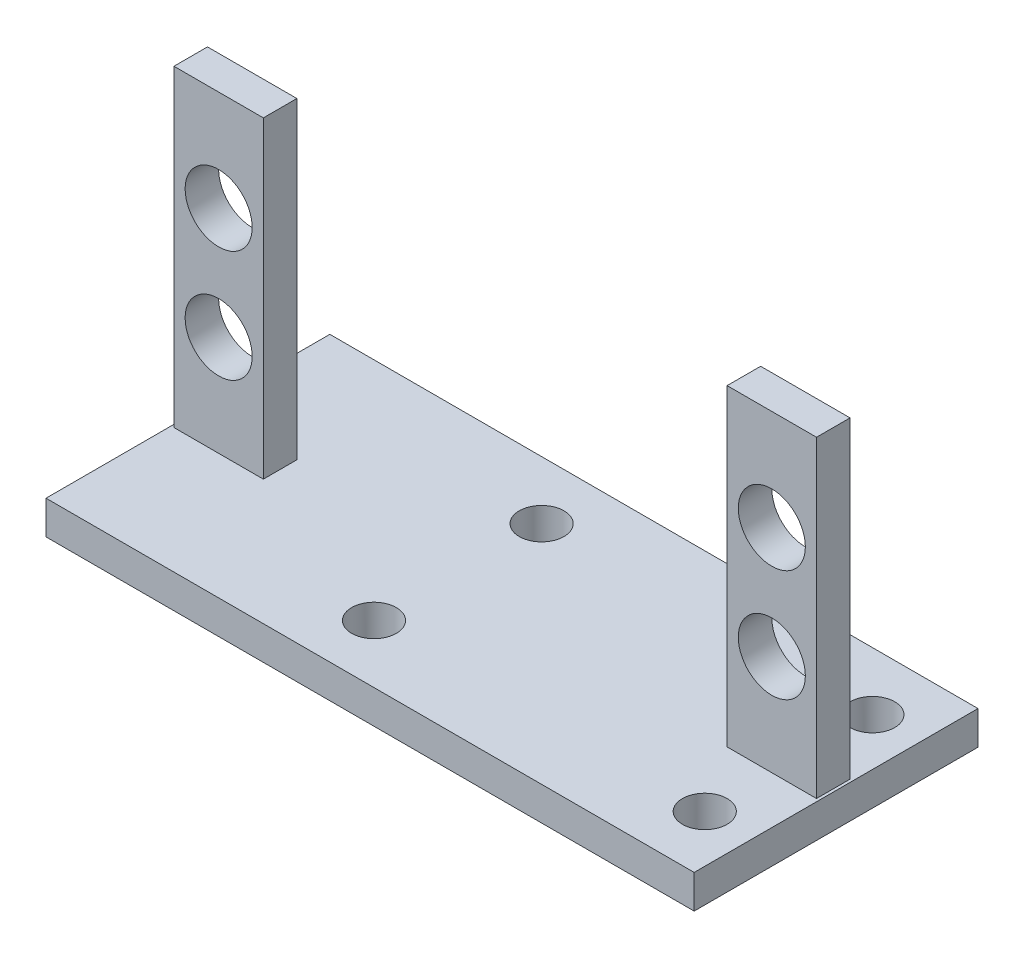
from build123d import *

# Parameters (mm, degrees)
SKETCH_1_W          = 58
SKETCH_1_H          = 25.4
EXTRUDE_1_DEPTH     = 3
SKETCH_2_W          = 8
SKETCH_2_H          = 3
EXTRUDE_2_DEPTH     = 28
SKETCH_3_R          = 3
CUT_EXTRUDE_1_DEPTH = 12
SKETCH_4_R          = 2
CUT_EXTRUDE_2_DEPTH = 22
SKETCH_5_W          = 8
SKETCH_5_H          = 3
CUT_EXTRUDE_3_DEPTH = 28


with BuildPart() as part:
    # 草图1 → 凸台-拉伸1 (new body)
    with BuildSketch(Plane(origin=(0, 0, 0), x_dir=(1, 0, 0), z_dir=(0, 1, 0))):
        Rectangle(SKETCH_1_W, SKETCH_1_H)
    extrude(amount=EXTRUDE_1_DEPTH)

    # 草图2 → 凸台-拉伸2 (add)
    with BuildSketch(Plane(origin=(0, 3, 0), x_dir=(1, 0, 0), z_dir=(0, 1, 0))):
        with Locations((-24.75, 11.2)):
            Rectangle(SKETCH_2_W, SKETCH_2_H)
        with Locations((24.75, 11.2)):
            Rectangle(SKETCH_2_W, SKETCH_2_H)
        with Locations((-24.75, 0)):
            Rectangle(SKETCH_2_W, SKETCH_2_H)
        with Locations((24.75, 0)):
            Rectangle(SKETCH_2_W, SKETCH_2_H)
    extrude(amount=EXTRUDE_2_DEPTH)

    # 草图3 → 切除-拉伸1 (cut, symmetric)
    with BuildSketch(Plane.XY.offset(-9.7)):
        with Locations((-24.75, 12)):
            Circle(SKETCH_3_R)
        with Locations((-24.75, 22)):
            Circle(SKETCH_3_R)
        with Locations((24.75, 12)):
            Circle(SKETCH_3_R)
        with Locations((24.75, 22)):
            Circle(SKETCH_3_R)
    extrude(amount=CUT_EXTRUDE_1_DEPTH, both=True, mode=Mode.SUBTRACT)

    # 草图4 → 切除-拉伸2 (cut)
    with BuildSketch(Plane(origin=(0, 3, 0), x_dir=(1, 0, 0), z_dir=(0, 1, 0))):
        with Locations((24.75, -7.5)):
            Circle(SKETCH_4_R)
        with Locations((24.75, 7.5)):
            Circle(SKETCH_4_R)
        with Locations((-4.85, 7.5)):
            Circle(SKETCH_4_R)
        with Locations((-4.85, -7.5)):
            Circle(SKETCH_4_R)
    extrude(amount=-CUT_EXTRUDE_2_DEPTH, mode=Mode.SUBTRACT)

    # 草图5 → 切除-拉伸3 (cut)
    with BuildSketch(Plane(origin=(0, 31, 0), x_dir=(1, 0, 0), z_dir=(0, 1, 0))):
        with Locations((-24.75, 11.2)):
            Rectangle(SKETCH_5_W, SKETCH_5_H)
        with Locations((24.75, 11.2)):
            Rectangle(SKETCH_5_W, SKETCH_5_H)
    extrude(amount=-CUT_EXTRUDE_3_DEPTH, mode=Mode.SUBTRACT)


solid = part.part
